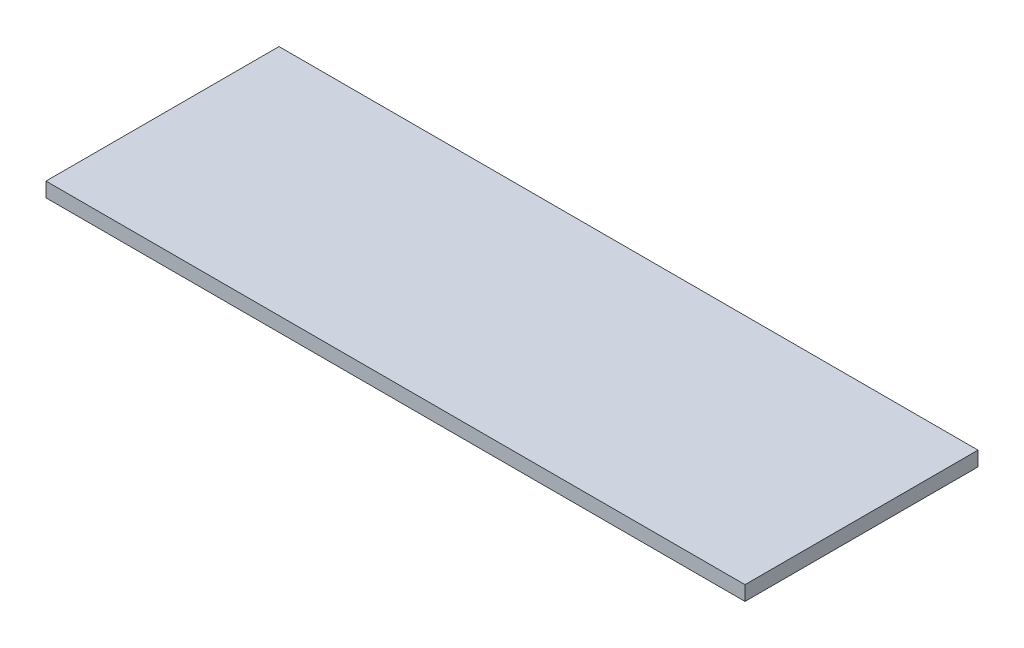
from build123d import *

# Parameters (mm, degrees)
SKETCH2_W           = 76.2
SKETCH2_H           = 25.4
BOSS_EXTRUDE1_DEPTH = 1.5875


with BuildPart() as part:
    # Sketch2 → Boss-Extrude1 (new body)
    with BuildSketch(Plane(origin=(0, 0, 0), x_dir=(1, 0, 0), z_dir=(0, 1, 0))):
        with Locations((38.1, 12.7)):
            Rectangle(SKETCH2_W, SKETCH2_H)
    extrude(amount=BOSS_EXTRUDE1_DEPTH)


solid = part.part
